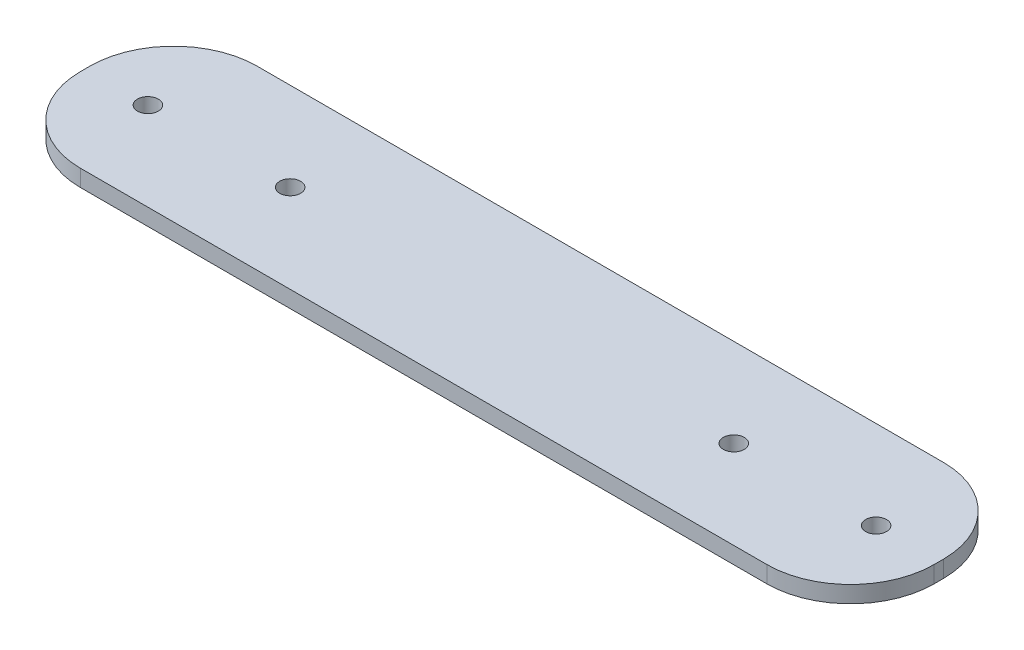
from build123d import *

# Parameters (mm, degrees)
SKETCH1_W           = 102
SKETCH1_H           = 21.11675127
SKETCH1_R           = 1.25
BOSS_EXTRUDE1_DEPTH = 2
FILLET1_R           = 10


with BuildPart() as part:
    # Sketch1 → Boss-Extrude1 (new body)
    with BuildSketch(Plane(origin=(0, 0, 0), x_dir=(1, 0, 0), z_dir=(0, 1, 0))):
        Rectangle(SKETCH1_W, SKETCH1_H)
        with Locations((43.5, 0)):
            Circle(SKETCH1_R, mode=Mode.SUBTRACT)
        with Locations((26.5, 0)):
            Circle(SKETCH1_R, mode=Mode.SUBTRACT)
        with Locations((-26.5, 0)):
            Circle(SKETCH1_R, mode=Mode.SUBTRACT)
        with Locations((-43.5, 0)):
            Circle(SKETCH1_R, mode=Mode.SUBTRACT)
    extrude(amount=BOSS_EXTRUDE1_DEPTH)

    # Fillet1
    fillet1_edges = [part.edges().sort_by_distance(p)[0] for p in [
        (-51, 1, -10.558375635),
        (51, 1, -10.558375635),
        (51, 1, 10.558375635),
        (-51, 1, 10.558375635),
    ]]
    fillet(fillet1_edges, radius=FILLET1_R)


solid = part.part
